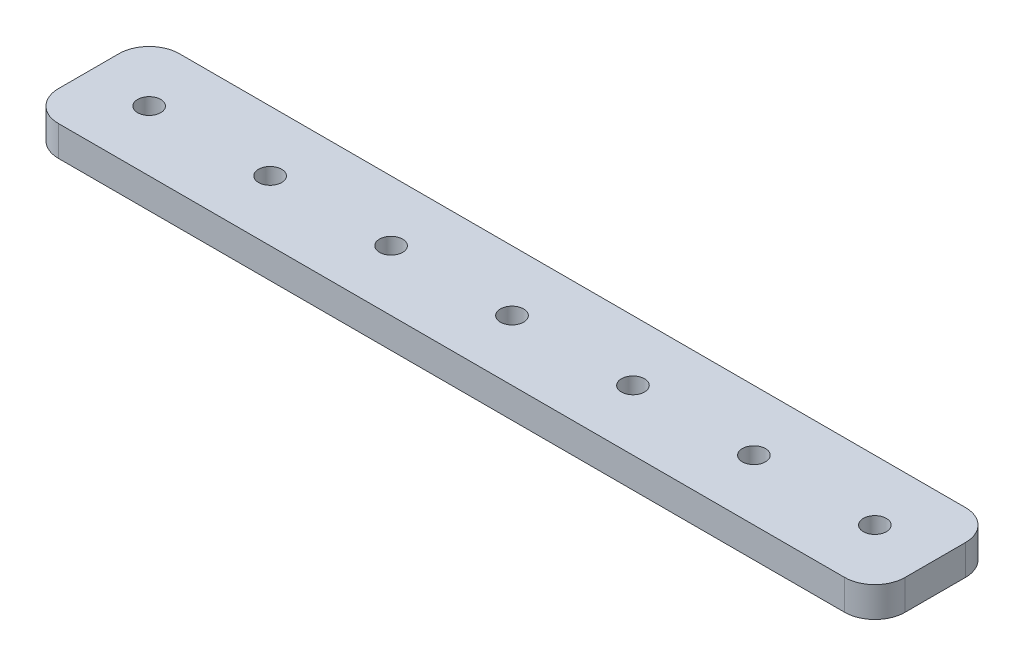
from build123d import *

# Parameters (mm, degrees)
SKETCH1_W           = 177.8
SKETCH1_H           = 25.4
BOSS_EXTRUDE1_DEPTH = 6.35
SKETCH2_R           = 2.425
CUT_EXTRUDE1_DEPTH  = 6.35
FILLET1_R           = 6.35


with BuildPart() as part:
    # Sketch1 → Boss-Extrude1 (new body)
    with BuildSketch(Plane(origin=(0, 0, 0), x_dir=(1, 0, 0), z_dir=(0, 1, 0))):
        with Locations((88.9, 12.7)):
            Rectangle(SKETCH1_W, SKETCH1_H)
    extrude(amount=BOSS_EXTRUDE1_DEPTH)

    # Sketch2 → Cut-Extrude1 (cut)
    with BuildSketch(Plane(origin=(0, 6.35, 0), x_dir=(1, 0, 0), z_dir=(0, 1, 0))):
        with Locations((12.7, 12.7)):
            Circle(SKETCH2_R)
        with Locations((38.1, 12.7)):
            Circle(SKETCH2_R)
        with Locations((63.5, 12.7)):
            Circle(SKETCH2_R)
        with Locations((88.9, 12.7)):
            Circle(SKETCH2_R)
        with Locations((114.3, 12.7)):
            Circle(SKETCH2_R)
        with Locations((139.7, 12.7)):
            Circle(SKETCH2_R)
        with Locations((165.1, 12.7)):
            Circle(SKETCH2_R)
    extrude(amount=-CUT_EXTRUDE1_DEPTH, mode=Mode.SUBTRACT)

    # Fillet1
    fillet1_edges = [part.edges().sort_by_distance(p)[0] for p in [
        (0, 3.175, -25.4),
        (177.8, 3.175, -25.4),
        (177.8, 3.175, 0),
        (0, 3.175, 0),
    ]]
    fillet(fillet1_edges, radius=FILLET1_R)


solid = part.part
